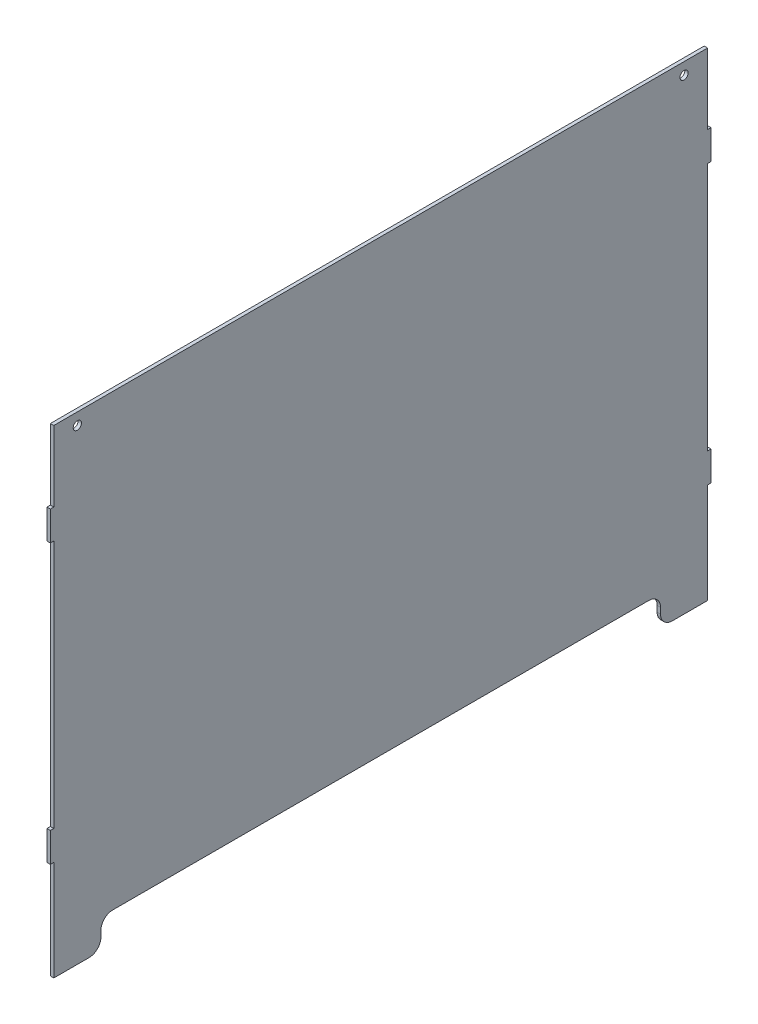
from build123d import *

# Parameters (mm, degrees)
BOSS_EXTRUDE1_DEPTH = 2.9
SKETCH2_R           = 3.5
CUT_EXTRUDE1_DEPTH  = 3.9


with BuildPart() as part:
    # Sketch1 → Boss-Extrude1 (new body)
    with BuildSketch(Plane(origin=(0, 0, 0), x_dir=(0, 0, -1), z_dir=(1, 0, 0))):
        with BuildLine():
            Line((247.65, -203.2), (277.65, -203.2))
            Line((277.65, -203.2), (277.65, -118.2))
            Line((277.65, -118.2), (280.55, -118.2))
            Line((280.55, -118.2), (280.55, -93.2))
            Line((280.55, -93.2), (277.65, -93.2))
            Line((277.65, -93.2), (277.65, 118.2))
            Line((277.65, 118.2), (280.55, 118.2))
            Line((280.55, 118.2), (280.55, 143.2))
            Line((280.55, 143.2), (277.65, 143.2))
            Line((277.65, 143.2), (277.65, 203.2))
            Line((277.65, 203.2), (-277.65, 203.2))
            Line((-277.65, 203.2), (-277.65, 143.2))
            Line((-277.65, 143.2), (-280.55, 143.2))
            Line((-280.55, 143.2), (-280.55, 118.2))
            Line((-280.55, 118.2), (-277.65, 118.2))
            Line((-277.65, 118.2), (-277.65, -93.2))
            Line((-277.65, -93.2), (-280.55, -93.2))
            Line((-280.55, -93.2), (-280.55, -118.2))
            Line((-280.55, -118.2), (-277.65, -118.2))
            Line((-277.65, -118.2), (-277.65, -203.2))
            Line((-277.65, -203.2), (-247.65, -203.2))
            ThreePointArc((-247.65, -203.2), (-240.578932188, -200.271067812), (-237.65, -193.2))
            Line((-237.65, -193.2), (-237.65, -188.2))
            ThreePointArc((-237.65, -188.2), (-234.721067812, -181.128932188), (-227.65, -178.2))
            Line((-227.65, -178.2), (227.65, -178.2))
            ThreePointArc((227.65, -178.2), (234.721067812, -181.128932188), (237.65, -188.2))
            Line((237.65, -188.2), (237.65, -193.2))
            ThreePointArc((237.65, -193.2), (240.578932188, -200.271067812), (247.65, -203.2))
        make_face()
    extrude(amount=BOSS_EXTRUDE1_DEPTH)

    # Sketch2 → Cut-Extrude1 (cut, through all)
    with BuildSketch(Plane(origin=(2.9, 0, 0), x_dir=(0, 0, -1), z_dir=(1, 0, 0))):
        with Locations((-257.65, 193.2)):
            Circle(SKETCH2_R)
        with Locations((257.65, 193.2)):
            Circle(SKETCH2_R)
    extrude(amount=-CUT_EXTRUDE1_DEPTH, mode=Mode.SUBTRACT)


solid = part.part
